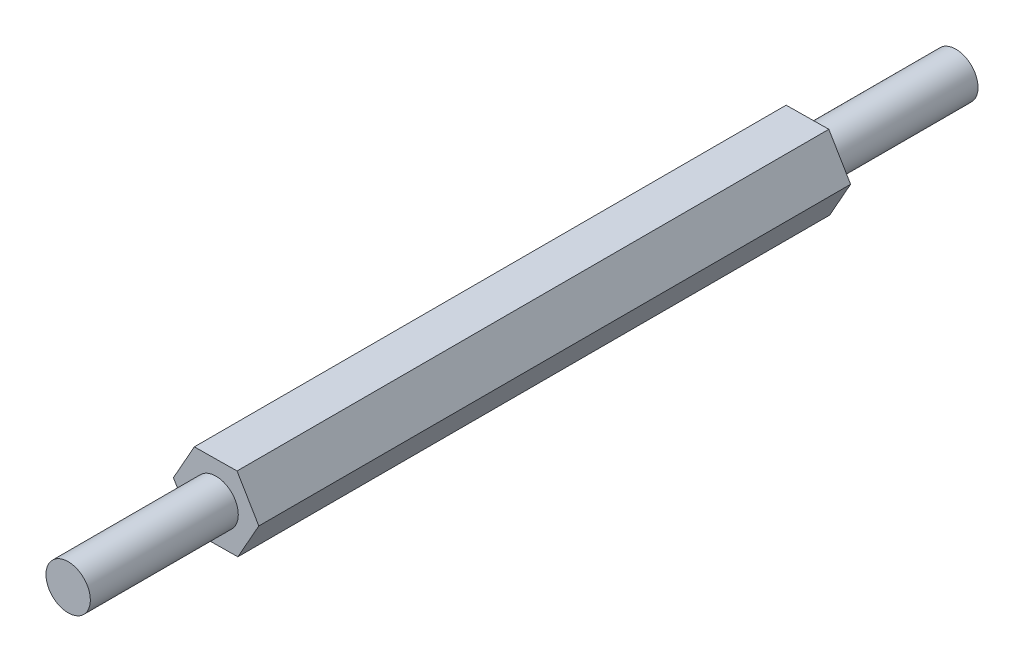
from build123d import *

# Parameters (mm, degrees)
BOSS_EXTRU_1_DEPTH = 40
ESQUISSE2_R        = 1.5
BOSS_EXTRU_2_DEPTH = 10
ESQUISSE3_R        = 1.5
BOSS_EXTRU_3_DEPTH = 10


with BuildPart() as part:
    # Esquisse1 → Boss.-Extru.1 (new body)
    with BuildSketch(Plane.XY):
        Polygon((1.470451141, -2.484171245), (2.886580976, 0.03136242), (1.416129835, 2.515533666), (-1.470451141, 2.484171245), (-2.886580976, -0.03136242), (-1.416129835, -2.515533666), align=None)
    extrude(amount=BOSS_EXTRU_1_DEPTH)

    # Esquisse2 → Boss.-Extru.2 (add)
    with BuildSketch(Plane.XY.offset(40)):
        Circle(ESQUISSE2_R)
    extrude(amount=BOSS_EXTRU_2_DEPTH)

    # Esquisse3 → Boss.-Extru.3 (add)
    with BuildSketch(Plane(origin=(0, 0, 0), x_dir=(-1, 0, 0), z_dir=(0, 0, -1))):
        Circle(ESQUISSE3_R)
    extrude(amount=BOSS_EXTRU_3_DEPTH)


solid = part.part
